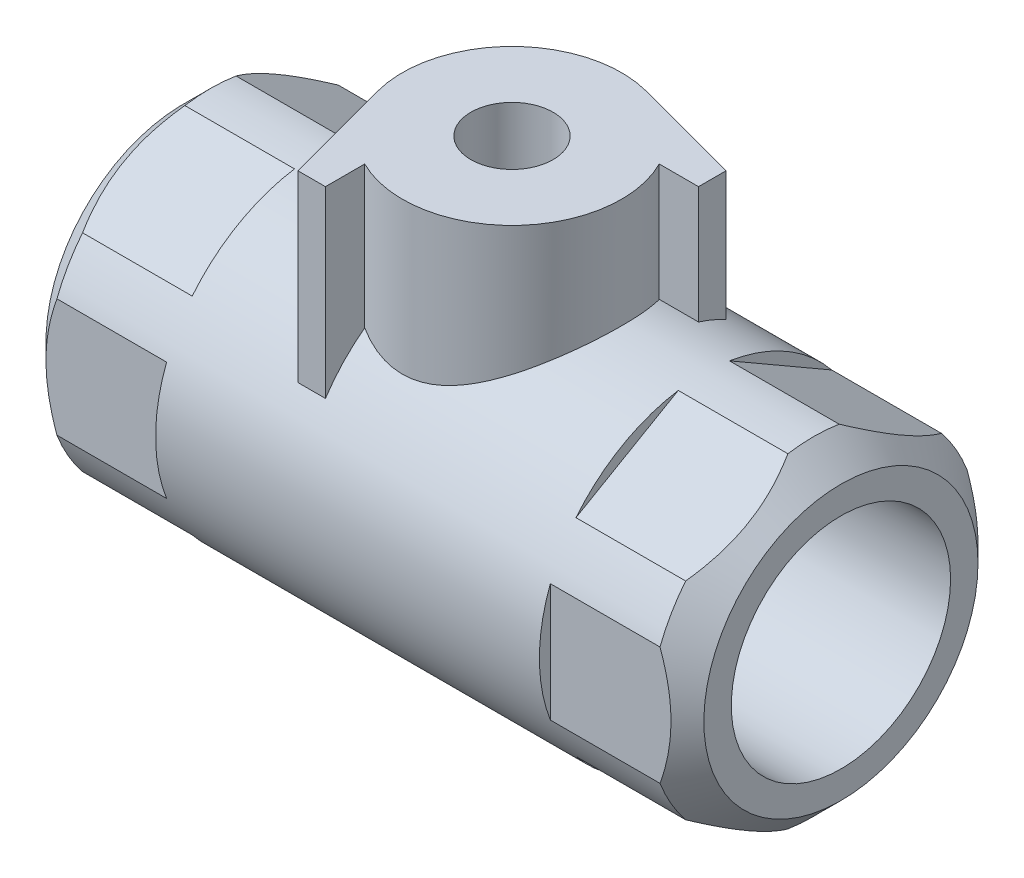
from build123d import *

# Parameters (mm, degrees)
SKETCH1_R                = 30
BOSS_EXTRUDE1_DEPTH      = 60
CHAMFER1_SIZE            = 5
CUT_EXTRUDE1_DEPTH       = 25
CIRPATTERN1_COUNT        = 6
SKETCH3_R                = 20
CUT_EXTRUDE2_DEPTH       = 30
SKETCH5_R                = 12.5
CUT_EXTRUDE3_DEPTH       = 91
CHAMFER2_SIZE            = 5
MIRROR1_COPY_1_DEPTH     = 25
MIRROR1_COPY_2_DEPTH     = 25
MIRROR1_COPY_3_DEPTH     = 25
MIRROR1_COPY_4_DEPTH     = 25
MIRROR1_COPY_5_DEPTH     = 25
CHAMFER2_OF_MIRROR1_SIZE = 5
BOSS_EXTRUDE2_REACH      = 82
BOSS_EXTRUDE2_END_RADIUS = 30
CUT_EXTRUDE4_REACH       = 82
CUT_EXTRUDE4_END_RADIUS  = 17
SKETCH8_R                = 7.5


with BuildPart() as part:
    # Sketch1 → Boss-Extrude1 (new body, symmetric)
    with BuildSketch(Plane(origin=(0, 0, 0), x_dir=(0, 0, -1), z_dir=(1, 0, 0))):
        Circle(SKETCH1_R)
    extrude(amount=BOSS_EXTRUDE1_DEPTH, both=True)

    # Chamfer1
    chamfer1_edges = [part.edges().sort_by_distance(p)[0] for p in [
        (-60, 0, 30),
        (60, 0, 30),
    ]]
    chamfer(chamfer1_edges, length=CHAMFER1_SIZE)

    # Sketch2 → Cut-Extrude1 (cut)
    with BuildSketch(Plane(origin=(60, 0, 0), x_dir=(0, 0, -1), z_dir=(1, 0, 0))):
        with BuildLine():
            Line((28, 10.770329614), (28, -10.770329614))
            ThreePointArc((28, -10.770329614), (30, 0), (28, 10.770329614))
        make_face()
    cut_extrude1 = extrude(amount=-CUT_EXTRUDE1_DEPTH, mode=Mode.SUBTRACT)

    # CirPattern1: Cut-Extrude1 ×6 about axis
    cirpattern1_axis = Axis((0, 0, 0), (1, 0, 0))
    for i in range(1, CIRPATTERN1_COUNT):
        add(cut_extrude1.rotate(cirpattern1_axis, i * 360 / CIRPATTERN1_COUNT), mode=Mode.SUBTRACT)

    # Sketch3 → Cut-Extrude2 (cut)
    with BuildSketch(Plane(origin=(60, 0, 0), x_dir=(0, 0, -1), z_dir=(1, 0, 0))):
        Circle(SKETCH3_R)
    cut_extrude2 = extrude(amount=-CUT_EXTRUDE2_DEPTH, mode=Mode.SUBTRACT)

    # Sketch5 → Cut-Extrude3 (cut, through all)
    with BuildSketch(Plane(origin=(30, 0, 0), x_dir=(0, 0, -1), z_dir=(1, 0, 0))):
        Circle(SKETCH5_R)
    extrude(amount=-CUT_EXTRUDE3_DEPTH, mode=Mode.SUBTRACT)

    # Sketch4 → Cut-Revolve1 (revolve, cut)
    with BuildSketch(Plane.XY):
        with BuildLine():
            Line((0, 17), (0, -17))
            ThreePointArc((0, -17), (17, 0), (0, 17))
        make_face()
    revolve(axis=Axis((0, 40.549893096, 0), (0, -1, 0)), mode=Mode.SUBTRACT)

    # Chamfer2
    chamfer2_edges = [part.edges().sort_by_distance(p)[0] for p in [
        (30, 0, 12.5),
    ]]
    chamfer(chamfer2_edges, length=CHAMFER2_SIZE)

    # Mirror1: Cut-Extrude1, Cut-Extrude2 across plane
    add(cut_extrude1.mirror(Plane(origin=(0, 0, 0), x_dir=(0, 0, 1), z_dir=(1, 0, 0))), mode=Mode.SUBTRACT)
    add(cut_extrude2.mirror(Plane(origin=(0, 0, 0), x_dir=(0, 0, 1), z_dir=(1, 0, 0))), mode=Mode.SUBTRACT)

    # Mirror1 copy 1 sketch → Mirror1 copy 1 (cut)
    with BuildSketch(Plane(origin=(-60, 0, 0), x_dir=(0, 0.866025404, -0.5), z_dir=(-1, 0, 0))):
        with BuildLine():
            Line((28, -10.770329614), (28, 10.770329614))
            ThreePointArc((28, 10.770329614), (30, 0), (28, -10.770329614))
        make_face()
    extrude(amount=-MIRROR1_COPY_1_DEPTH, mode=Mode.SUBTRACT)

    # Mirror1 copy 2 sketch → Mirror1 copy 2 (cut)
    with BuildSketch(Plane(origin=(-60, 0, 0), x_dir=(0, 0.866025404, 0.5), z_dir=(-1, 0, 0))):
        with BuildLine():
            Line((28, -10.770329614), (28, 10.770329614))
            ThreePointArc((28, 10.770329614), (30, 0), (28, -10.770329614))
        make_face()
    extrude(amount=-MIRROR1_COPY_2_DEPTH, mode=Mode.SUBTRACT)

    # Mirror1 copy 3 sketch → Mirror1 copy 3 (cut)
    with BuildSketch(Plane.ZY.offset(60)):
        with BuildLine():
            Line((28, -10.770329614), (28, 10.770329614))
            ThreePointArc((28, 10.770329614), (30, 0), (28, -10.770329614))
        make_face()
    extrude(amount=-MIRROR1_COPY_3_DEPTH, mode=Mode.SUBTRACT)

    # Mirror1 copy 4 sketch → Mirror1 copy 4 (cut)
    with BuildSketch(Plane(origin=(-60, 0, 0), x_dir=(0, -0.866025404, 0.5), z_dir=(-1, 0, 0))):
        with BuildLine():
            Line((28, -10.770329614), (28, 10.770329614))
            ThreePointArc((28, 10.770329614), (30, 0), (28, -10.770329614))
        make_face()
    extrude(amount=-MIRROR1_COPY_4_DEPTH, mode=Mode.SUBTRACT)

    # Mirror1 copy 5 sketch → Mirror1 copy 5 (cut)
    with BuildSketch(Plane(origin=(-60, 0, 0), x_dir=(0, -0.866025404, -0.5), z_dir=(-1, 0, 0))):
        with BuildLine():
            Line((28, -10.770329614), (28, 10.770329614))
            ThreePointArc((28, 10.770329614), (30, 0), (28, -10.770329614))
        make_face()
    extrude(amount=-MIRROR1_COPY_5_DEPTH, mode=Mode.SUBTRACT)

    # Chamfer2 of Mirror1
    chamfer2_of_mirror1_edges = [part.edges().sort_by_distance(p)[0] for p in [
        (-30, 0, 12.5),
    ]]
    chamfer(chamfer2_of_mirror1_edges, length=CHAMFER2_OF_MIRROR1_SIZE)

    # Boss-Extrude2: up to this cylinder (the profile starts outside it)
    boss_extrude2_end = Plane(origin=(0.286485, 0, 0), z_dir=(-1, 0, 0)) * Cylinder(BOSS_EXTRUDE2_END_RADIUS, 225, mode=Mode.PRIVATE)
    # Sketch6 → Boss-Extrude2 (add, up to the surface)
    with BuildSketch(Plane(origin=(0, 50, 0), x_dir=(1, 0, 0), z_dir=(0, 1, 0)), mode=Mode.PRIVATE) as boss_extrude2_sk1:
        with BuildLine():
            Line((17.860571099, 9), (25.025354797, 9))
            Line((25.025354797, 9), (25.025354797, 14))
            Line((25.025354797, 14), (5.176380902, 19.318516526))
            ThreePointArc((5.176380902, 19.318516526), (-14.142135624, 14.142135624), (-19.318516526, -5.176380902))
            Line((-19.318516526, -5.176380902), (-14, -25.025354797))
            Line((-14, -25.025354797), (-9, -25.025354797))
            Line((-9, -25.025354797), (-9, -17.860571099))
            ThreePointArc((-9, -17.860571099), (14.142135624, -14.142135624), (17.860571099, 9))
        make_face()
    boss_extrude2_tool1 = extrude(boss_extrude2_sk1.sketch, amount=-BOSS_EXTRUDE2_REACH, mode=Mode.PRIVATE) - boss_extrude2_end
    add(boss_extrude2_tool1.solids().sort_by_distance((0.286485, 50, 0.286485))[0])

    # Cut-Extrude4: up to this sphere (the profile starts outside it)
    cut_extrude4_end = Location((0, 0, 0)) * Sphere(CUT_EXTRUDE4_END_RADIUS, mode=Mode.PRIVATE)
    # Sketch8 → Cut-Extrude4 (cut, up to the surface)
    with BuildSketch(Plane(origin=(0, 50, 0), x_dir=(1, 0, 0), z_dir=(0, 1, 0)), mode=Mode.PRIVATE) as cut_extrude4_sk1:
        with Locations(Location((0, 0, 0), (0, 0, 270))):  # turned: the seam where the file's is
            Circle(SKETCH8_R)
    cut_extrude4_tool1 = extrude(cut_extrude4_sk1.sketch, amount=-CUT_EXTRUDE4_REACH, mode=Mode.PRIVATE) - cut_extrude4_end
    add(cut_extrude4_tool1.solids().sort_by_distance((0, 50, 0))[0], mode=Mode.SUBTRACT)


solid = part.part
